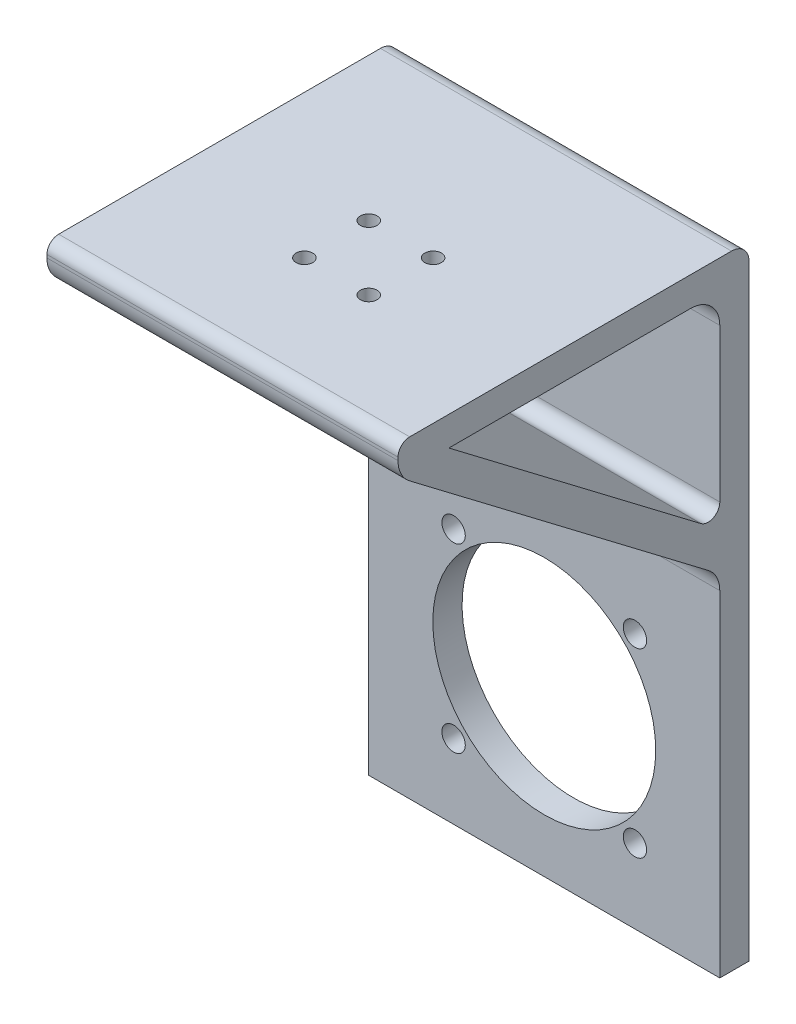
from build123d import *

# Parameters (mm, degrees)
BOSS_EXTRUDE1_DEPTH = 60
CUT_EXTRUDE2_REACH  = 108.6
SKETCH2_R           = 1.425
CUT_EXTRUDE3_REACH  = 62
SKETCH7_R           = 2
SKETCH7_R_2         = 19.05
FILLET2_R           = 5
FILLET4_R           = 5
FILLET5_R           = 2
FILLET6_R           = 2
FILLET7_R           = 3
FILLET8_R           = 5


with BuildPart() as part:
    # Sketch1 → Boss-Extrude1 (new body)
    with BuildSketch(Plane(origin=(0, 0, 0), x_dir=(0, 0, -1), z_dir=(1, 0, 0))):
        Polygon((-20.469264339, 47.094964584), (-20.469264339, 52.094964584), (39.530735661, 52.094964584), (39.530735661, -54.505035416), (34.530735661, -54.505035416), (34.530735661, 5.314612494), align=None)
        Polygon((-11.77256872, 47.094964584), (34.530735661, 11.920994403), (34.530735661, 47.094964584), align=None, mode=Mode.SUBTRACT)
    extrude(amount=-BOSS_EXTRUDE1_DEPTH)

    # Sketch2 → Cut-Extrude2 (cut, up to next)
    with BuildSketch(Plane(origin=(0, 52.094964584, 0), x_dir=(1, 0, 0), z_dir=(0, 1, 0)), mode=Mode.PRIVATE) as cut_extrude2_sk1:
        with Locations((-35.5, 10.030735661)):
            Circle(SKETCH2_R)
    cut_extrude2_tool1 = extrude(cut_extrude2_sk1.sketch, amount=-CUT_EXTRUDE2_REACH, mode=Mode.PRIVATE) & part.part
    add(cut_extrude2_tool1.solids().sort_by_distance((-35.5, 52.094965, -10.030736))[0], mode=Mode.SUBTRACT)
    # Sketch2 → Cut-Extrude2 (cut, up to next)
    with BuildSketch(Plane(origin=(0, 52.094964584, 0), x_dir=(1, 0, 0), z_dir=(0, 1, 0)), mode=Mode.PRIVATE) as cut_extrude2_sk2:
        with Locations((-24.5, 10.030735661)):
            Circle(SKETCH2_R)
    cut_extrude2_tool2 = extrude(cut_extrude2_sk2.sketch, amount=-CUT_EXTRUDE2_REACH, mode=Mode.PRIVATE) & part.part
    add(cut_extrude2_tool2.solids().sort_by_distance((-24.5, 52.094965, -10.030736))[0], mode=Mode.SUBTRACT)
    # Sketch2 → Cut-Extrude2 (cut, up to next)
    with BuildSketch(Plane(origin=(0, 52.094964584, 0), x_dir=(1, 0, 0), z_dir=(0, 1, 0)), mode=Mode.PRIVATE) as cut_extrude2_sk3:
        with Locations((-24.5, -0.969264339)):
            Circle(SKETCH2_R)
    cut_extrude2_tool3 = extrude(cut_extrude2_sk3.sketch, amount=-CUT_EXTRUDE2_REACH, mode=Mode.PRIVATE) & part.part
    add(cut_extrude2_tool3.solids().sort_by_distance((-24.5, 52.094965, 0.969264))[0], mode=Mode.SUBTRACT)
    # Sketch2 → Cut-Extrude2 (cut, up to next)
    with BuildSketch(Plane(origin=(0, 52.094964584, 0), x_dir=(1, 0, 0), z_dir=(0, 1, 0)), mode=Mode.PRIVATE) as cut_extrude2_sk4:
        with Locations((-35.5, -0.969264339)):
            Circle(SKETCH2_R)
    cut_extrude2_tool4 = extrude(cut_extrude2_sk4.sketch, amount=-CUT_EXTRUDE2_REACH, mode=Mode.PRIVATE) & part.part
    add(cut_extrude2_tool4.solids().sort_by_distance((-35.5, 52.094965, 0.969264))[0], mode=Mode.SUBTRACT)

    # Sketch7 → Cut-Extrude3 (cut, up to next)
    with BuildSketch(Plane(origin=(0, 0, -39.530735661), x_dir=(-1, 0, 0), z_dir=(0, 0, -1)), mode=Mode.PRIVATE) as cut_extrude3_sk1:
        with Locations((14.5, -10.805035416)):
            Circle(SKETCH7_R)
    cut_extrude3_tool1 = extrude(cut_extrude3_sk1.sketch, amount=-CUT_EXTRUDE3_REACH, mode=Mode.PRIVATE) & part.part
    add(cut_extrude3_tool1.solids().sort_by_distance((-14.5, -10.805035, -39.530736))[0], mode=Mode.SUBTRACT)
    # Sketch7 → Cut-Extrude3 (cut, up to next)
    with BuildSketch(Plane(origin=(0, 0, -39.530735661), x_dir=(-1, 0, 0), z_dir=(0, 0, -1)), mode=Mode.PRIVATE) as cut_extrude3_sk2:
        with Locations((45.5, -10.805035416)):
            Circle(SKETCH7_R)
    cut_extrude3_tool2 = extrude(cut_extrude3_sk2.sketch, amount=-CUT_EXTRUDE3_REACH, mode=Mode.PRIVATE) & part.part
    add(cut_extrude3_tool2.solids().sort_by_distance((-45.5, -10.805035, -39.530736))[0], mode=Mode.SUBTRACT)
    # Sketch7 → Cut-Extrude3 (cut, up to next)
    with BuildSketch(Plane(origin=(0, 0, -39.530735661), x_dir=(-1, 0, 0), z_dir=(0, 0, -1)), mode=Mode.PRIVATE) as cut_extrude3_sk3:
        with Locations((45.5, -41.805035416)):
            Circle(SKETCH7_R)
    cut_extrude3_tool3 = extrude(cut_extrude3_sk3.sketch, amount=-CUT_EXTRUDE3_REACH, mode=Mode.PRIVATE) & part.part
    add(cut_extrude3_tool3.solids().sort_by_distance((-45.5, -41.805035, -39.530736))[0], mode=Mode.SUBTRACT)
    # Sketch7 → Cut-Extrude3 (cut, up to next)
    with BuildSketch(Plane(origin=(0, 0, -39.530735661), x_dir=(-1, 0, 0), z_dir=(0, 0, -1)), mode=Mode.PRIVATE) as cut_extrude3_sk4:
        with Locations((14.5, -41.805035416)):
            Circle(SKETCH7_R)
    cut_extrude3_tool4 = extrude(cut_extrude3_sk4.sketch, amount=-CUT_EXTRUDE3_REACH, mode=Mode.PRIVATE) & part.part
    add(cut_extrude3_tool4.solids().sort_by_distance((-14.5, -41.805035, -39.530736))[0], mode=Mode.SUBTRACT)
    # Sketch7 → Cut-Extrude3 (cut, up to next)
    with BuildSketch(Plane(origin=(0, 0, -39.530735661), x_dir=(-1, 0, 0), z_dir=(0, 0, -1)), mode=Mode.PRIVATE) as cut_extrude3_sk5:
        with Locations((30, -26.305035416)):
            Circle(SKETCH7_R_2)
    cut_extrude3_tool5 = extrude(cut_extrude3_sk5.sketch, amount=-CUT_EXTRUDE3_REACH, mode=Mode.PRIVATE) & part.part
    add(cut_extrude3_tool5.solids().sort_by_distance((-30, -26.305035, -39.530736))[0], mode=Mode.SUBTRACT)

    # Fillet2
    fillet2_edges = [part.edges().sort_by_distance(p)[0] for p in [
        (-30, 47.094964584, -34.530735661),
    ]]
    fillet(fillet2_edges, radius=FILLET2_R)

    # Fillet4
    fillet4_edges = [part.edges().sort_by_distance(p)[0] for p in [
        (-30, 47.094964584, 20.469264339),
    ]]
    fillet(fillet4_edges, radius=FILLET4_R)

    # Fillet5
    fillet5_edges = [part.edges().sort_by_distance(p)[0] for p in [
        (-30, 11.920994403, -34.530735661),
    ]]
    fillet(fillet5_edges, radius=FILLET5_R)

    # Fillet6
    fillet6_edges = [part.edges().sort_by_distance(p)[0] for p in [
        (-30, 52.094964584, 20.469264339),
    ]]
    fillet(fillet6_edges, radius=FILLET6_R)

    # Fillet7
    fillet7_edges = [part.edges().sort_by_distance(p)[0] for p in [
        (-30, 52.094964584, -39.530735661),
    ]]
    fillet(fillet7_edges, radius=FILLET7_R)

    # Fillet8
    fillet8_edges = [part.edges().sort_by_distance(p)[0] for p in [
        (-30, 5.314612494, -34.530735661),
    ]]
    fillet(fillet8_edges, radius=FILLET8_R)


solid = part.part
